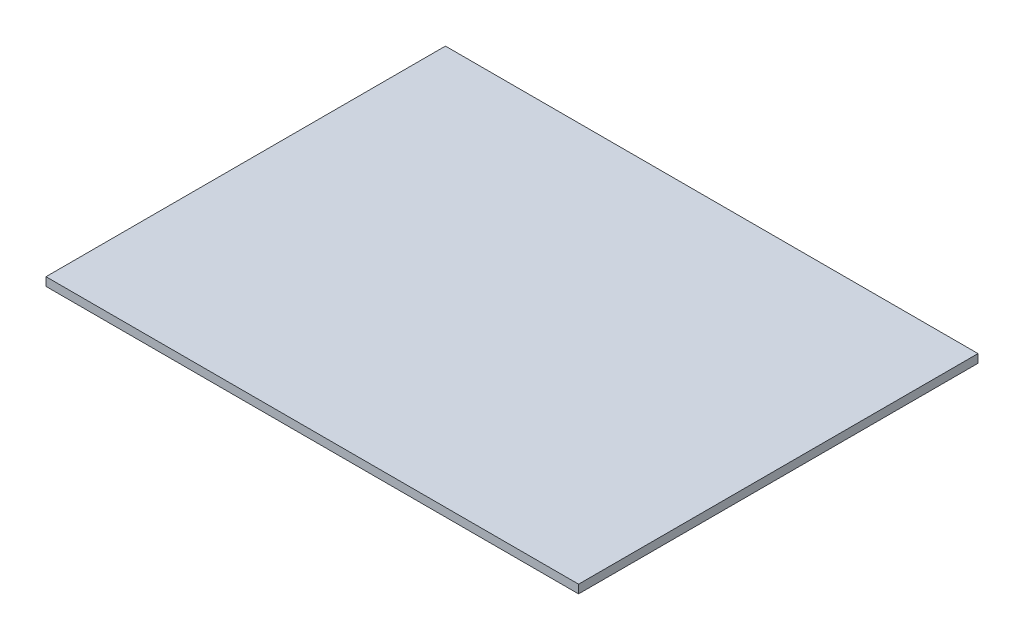
from build123d import *

# Parameters (mm, degrees)
SKETCH1_W           = 100
SKETCH1_H           = 75
BOSS_EXTRUDE1_DEPTH = 1.5875


with BuildPart() as part:
    # Sketch1 → Boss-Extrude1 (new body)
    with BuildSketch(Plane(origin=(0, 0, 0), x_dir=(1, 0, 0), z_dir=(0, 1, 0))):
        with Locations((50, 37.5)):
            Rectangle(SKETCH1_W, SKETCH1_H)
    extrude(amount=BOSS_EXTRUDE1_DEPTH)


solid = part.part
